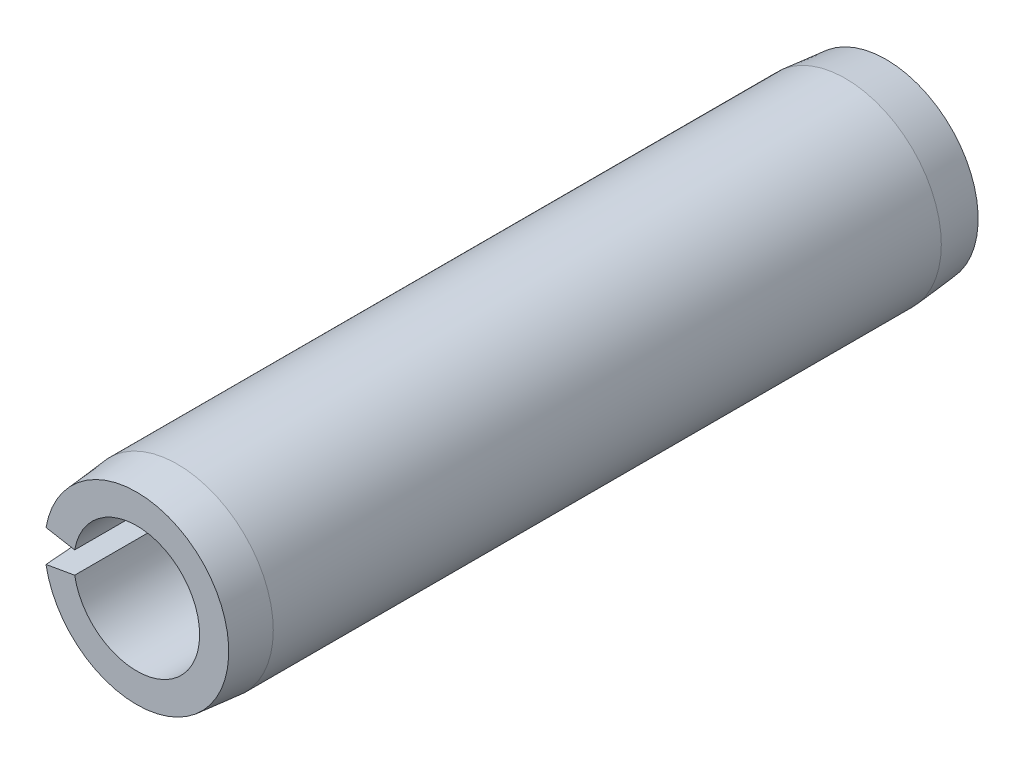
from build123d import *

# Parameters (mm, degrees)
EXTRUDE1_DEPTH = 22.225


with BuildPart() as part:
    # Sketch1 → Extrude1 (new body, symmetric)
    with BuildSketch(Plane.XY):
        with BuildLine():
            Line((-5.603162192, 0.987988672), (-3.677075188, 0.648367566))
            ThreePointArc((-3.677075188, 0.648367566), (3.7338, 0), (-3.677075188, -0.648367566))
            Line((-3.677075188, -0.648367566), (-5.603162192, -0.987988672))
            ThreePointArc((-5.603162192, -0.987988672), (5.6896, 0), (-5.603162192, 0.987988672))
        make_face()
    extrude(amount=EXTRUDE1_DEPTH, both=True)

    # Sketch2 → Cut-Revolve1 (revolve, cut)
    with BuildSketch(Plane(origin=(0, 0, 0), x_dir=(0, 0, -1), z_dir=(1, 0, 0))):
        Polygon((22.225, 5.6896), (22.225, 5.461), (19.812, 5.6896), align=None)
        Polygon((-19.812, 5.6896), (-22.225, 5.6896), (-22.225, 5.461), align=None)
    revolve(axis=Axis((0, 0, -22.225), (0, 0, 1)), mode=Mode.SUBTRACT)


solid = part.part
